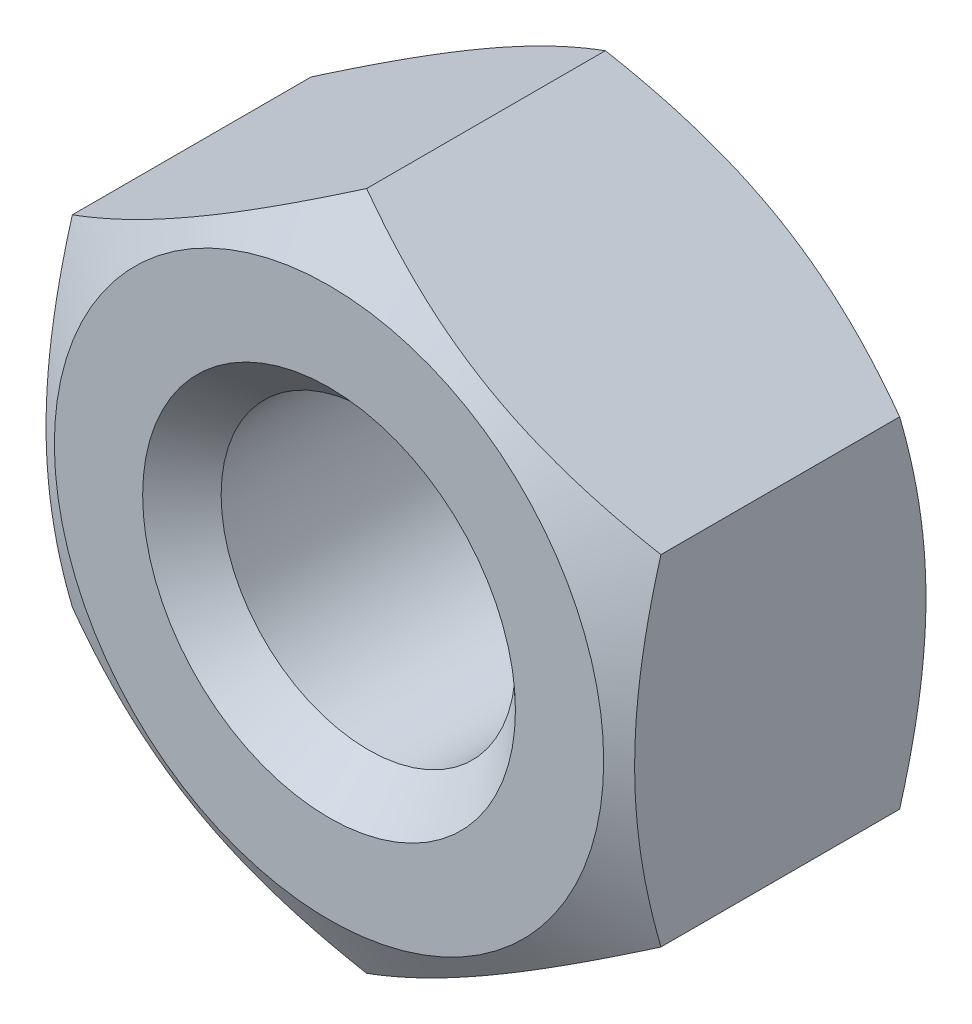
from build123d import *

# Parameters (mm, degrees)
SKETCH_1_W               = 5
SKETCH_1_H               = 3.2
SKETCH_2_OUTSIDE_W       = 14.9
SKETCH_2_OUTSIDE_H       = 14.9
CUT_EXTRUDE_1_DEPTH      = 3.2
SKETCH_3_R               = 1.5
CUT_EXTRUDE_2_DEPTH      = 1
CUT_EXTRUDE_2_DEPTH_BACK = 4.2
CHAMFER_1_SIZE           = 0.4


with BuildPart() as part:
    # Эскиз1 → Повернуть1 (revolve)
    with BuildSketch(Plane(origin=(0, 0, 0), x_dir=(1, 0, 0), z_dir=(0, 1, 0))):
        with Locations((-2.5, 1.6)):
            Rectangle(SKETCH_1_W, SKETCH_1_H)
    revolve(axis=Axis((0, 0, 0), (0, 0, -1)))

    # Эскиз2 outside → Вырез-Вытянуть1 (cut)
    with BuildSketch(Plane.XY):
        Rectangle(SKETCH_2_OUTSIDE_W, SKETCH_2_OUTSIDE_H)
        Polygon((3, -1.732050808), (3, 1.732050808), (0, 3.464101615), (-3, 1.732050808), (-3, -1.732050808), (0, -3.464101615), align=None, mode=Mode.SUBTRACT)
    extrude(amount=-CUT_EXTRUDE_1_DEPTH, mode=Mode.SUBTRACT)

    # Эскиз3 → Вырез-Вытянуть2 (cut, two sides)
    with BuildSketch(Plane.XY) as cut_extrude_2_sk:
        Circle(SKETCH_3_R)
    extrude(amount=CUT_EXTRUDE_2_DEPTH, mode=Mode.SUBTRACT)
    extrude(cut_extrude_2_sk.sketch, amount=-CUT_EXTRUDE_2_DEPTH_BACK, mode=Mode.SUBTRACT)

    # Эскиз4 → Вырез-Повернуть1 (revolve, cut)
    with BuildSketch(Plane(origin=(0, 0, 0), x_dir=(0, 0, -1), z_dir=(1, 0, 0))):
        Polygon((0, 2.8), (0.383419246, 3.464101615), (0, 3.464101615), align=None)
        Polygon((3.2, 2.8), (2.816580754, 3.464101615), (3.2, 3.464101615), align=None)
    revolve(axis=Axis((0, 0, 0), (0, 0, -1)), mode=Mode.SUBTRACT)

    # Фаска1
    chamfer_1_edges = [part.edges().sort_by_distance(p)[0] for p in [
        (-1.5, 0, -3.2),
        (-1.5, 0, 0),
    ]]
    chamfer(chamfer_1_edges, length=CHAMFER_1_SIZE)


solid = part.part
